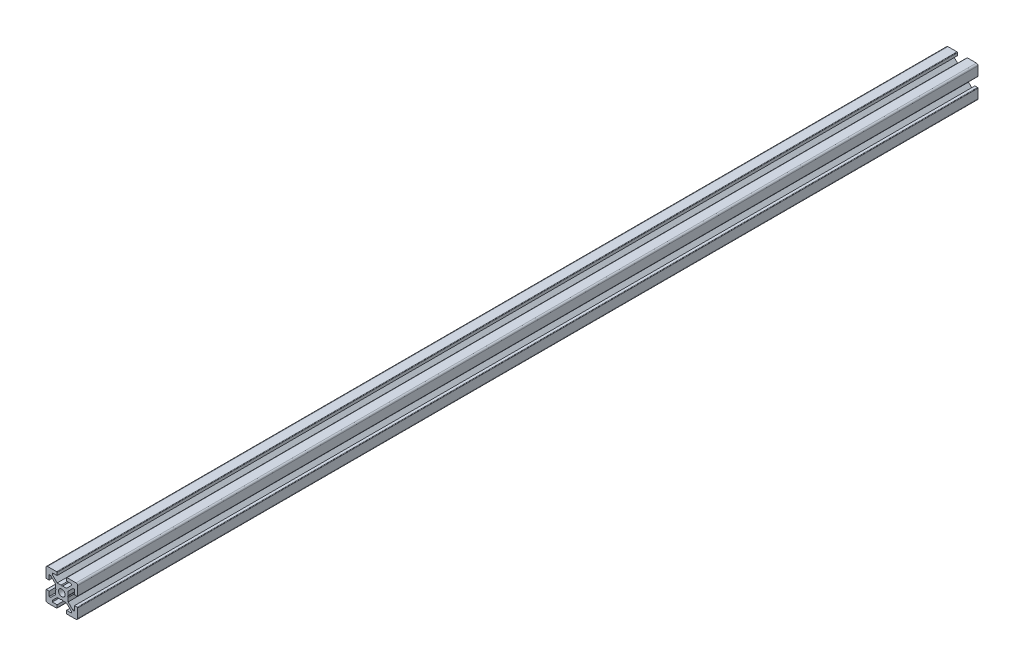
from build123d import *

# Parameters (mm, degrees)
BOSS_EXTRUDE1_DEPTH = 569.5
SKETCH2_W           = 609.5
SKETCH2_H           = 2.1
SKETCH3_R           = 2.5
CUT_EXTRUDE1_DEPTH  = 20


with BuildPart() as part:
    # Sketch1 → Boss-Extrude1 (new body)
    with BuildSketch(Plane.XY):
        with BuildLine():
            Line((-10, 9), (-10, 3.29999995))
            ThreePointArc((-10, 3.29999995), (-9.912132049, 3.087867916), (-9.7, 3))
            Line((-9.7, 3), (-8, 3))
            Line((-8, 3), (-8, 6))
            Line((-8, 6), (-7.060677, 6))
            Line((-7.060677, 6), (-4, 2.93932965))
            Line((-4, 2.93932965), (-4, 0.519615242))
            Line((-4, 0.519615242), (-3.699996283, -6.437e-06))
            Line((-3.699996283, -6.437e-06), (-4, -0.519628117))
            Line((-4, -0.519628117), (-4, -2.93933725))
            Line((-4, -2.93933725), (-7.0606695, -6))
            Line((-7.0606695, -6), (-8, -6))
            Line((-8, -6), (-8, -3))
            Line((-8, -3), (-9.7, -3))
            ThreePointArc((-9.7, -3), (-9.912132049, -3.087867916), (-10, -3.29999995))
            Line((-10, -3.29999995), (-10, -9))
            ThreePointArc((-10, -9), (-9.707106781, -9.707106781), (-9, -10))
            Line((-9, -10), (-3.29999995, -10))
            ThreePointArc((-3.29999995, -10), (-3.087867916, -9.912132049), (-3, -9.7))
            Line((-3, -9.7), (-3, -8))
            Line((-3, -8), (-6, -8))
            Line((-6, -8), (-6, -7.0606515))
            Line((-6, -7.0606515), (-2.9393489, -4))
            Line((-2.9393489, -4), (-0.519615242, -4))
            Line((-0.519615242, -4), (6.437e-06, -3.699996283))
            Line((6.437e-06, -3.699996283), (0.519628117, -4))
            Line((0.519628117, -4), (2.9393227, -4))
            Line((2.9393227, -4), (6, -7.060677))
            Line((6, -7.060677), (6, -8))
            Line((6, -8), (3, -8))
            Line((3, -8), (3, -9.7))
            ThreePointArc((3, -9.7), (3.087867916, -9.912132049), (3.29999995, -10))
            Line((3.29999995, -10), (9, -10))
            ThreePointArc((9, -10), (9.707106781, -9.707106781), (10, -9))
            Line((10, -9), (10, -3.29999995))
            ThreePointArc((10, -3.29999995), (9.912132049, -3.087867916), (9.7, -3))
            Line((9.7, -3), (8, -3))
            Line((8, -3), (8, -6))
            Line((8, -6), (7.0606435, -6))
            Line((7.0606435, -6), (4, -2.9393482))
            Line((4, -2.9393482), (4, -0.519615242))
            Line((4, -0.519615242), (3.699996283, 6.437e-06))
            Line((3.699996283, 6.437e-06), (4, 0.519628117))
            Line((4, 0.519628117), (4, 2.9393401))
            Line((4, 2.9393401), (7.060651, 6))
            Line((7.060651, 6), (8, 6))
            Line((8, 6), (8, 3))
            Line((8, 3), (9.7, 3))
            ThreePointArc((9.7, 3), (9.912132049, 3.087867916), (10, 3.29999995))
            Line((10, 3.29999995), (10, 9))
            ThreePointArc((10, 9), (9.707106781, 9.707106781), (9, 10))
            Line((9, 10), (3.29999995, 10))
            ThreePointArc((3.29999995, 10), (3.087867916, 9.912132049), (3, 9.7))
            Line((3, 9.7), (3, 8))
            Line((3, 8), (6, 8))
            Line((6, 8), (6, 7.060669))
            Line((6, 7.060669), (2.9393308, 4))
            Line((2.9393308, 4), (0.519615242, 4))
            Line((0.519615242, 4), (-6.437e-06, 3.699996283))
            Line((-6.437e-06, 3.699996283), (-0.519628117, 4))
            Line((-0.519628117, 4), (-2.93935655, 4))
            Line((-2.93935655, 4), (-6, 7.0606435))
            Line((-6, 7.0606435), (-6, 8))
            Line((-6, 8), (-3, 8))
            Line((-3, 8), (-3, 9.7))
            ThreePointArc((-3, 9.7), (-3.087867966, 9.912132034), (-3.3, 10))
            Line((-3.3, 10), (-9, 10))
            ThreePointArc((-9, 10), (-9.707106781, 9.707106781), (-10, 9))
        make_face()
    extrude(amount=-BOSS_EXTRUDE1_DEPTH)

    # Sketch2 → Cut-Revolve1 (revolve, cut)
    with BuildSketch(Plane(origin=(0, 0, 0), x_dir=(0, 0, -1), z_dir=(1, 0, 0))):
        with Locations((304.75, 1.05)):
            Rectangle(SKETCH2_W, SKETCH2_H)
    revolve(axis=Axis((0, 0, -609.5), (0, 0, 1)), mode=Mode.SUBTRACT)

    # Sketch3 → Cut-Extrude1 (cut)
    with BuildSketch(Plane(origin=(10, 0, 0), x_dir=(0, 0, -1), z_dir=(1, 0, 0))):
        with Locations((284.75, 0)):
            Circle(SKETCH3_R)
    extrude(amount=-CUT_EXTRUDE1_DEPTH, mode=Mode.SUBTRACT)


solid = part.part
